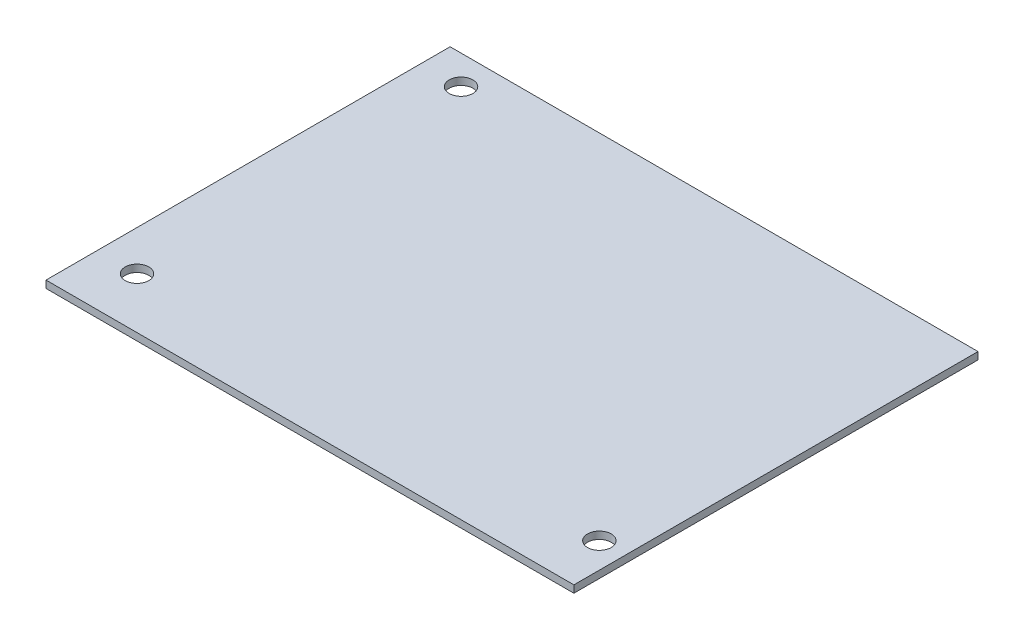
from build123d import *

# Parameters (mm, degrees)
SKETCH1_W           = 145
SKETCH1_H           = 111
SKETCH1_R           = 3.25
BOSS_EXTRUDE1_DEPTH = 2


with BuildPart() as part:
    # Sketch1 → Boss-Extrude1 (new body)
    with BuildSketch(Plane(origin=(0, 0, 0), x_dir=(1, 0, 0), z_dir=(0, 1, 0))):
        with Locations((-72.5, 55.5)):
            Rectangle(SKETCH1_W, SKETCH1_H)
        with Locations((-134, 14)):
            Circle(SKETCH1_R, mode=Mode.SUBTRACT)
        with Locations((-7, 14)):
            Circle(SKETCH1_R, mode=Mode.SUBTRACT)
        with Locations((-134, 103)):
            Circle(SKETCH1_R, mode=Mode.SUBTRACT)
    extrude(amount=BOSS_EXTRUDE1_DEPTH)


solid = part.part
